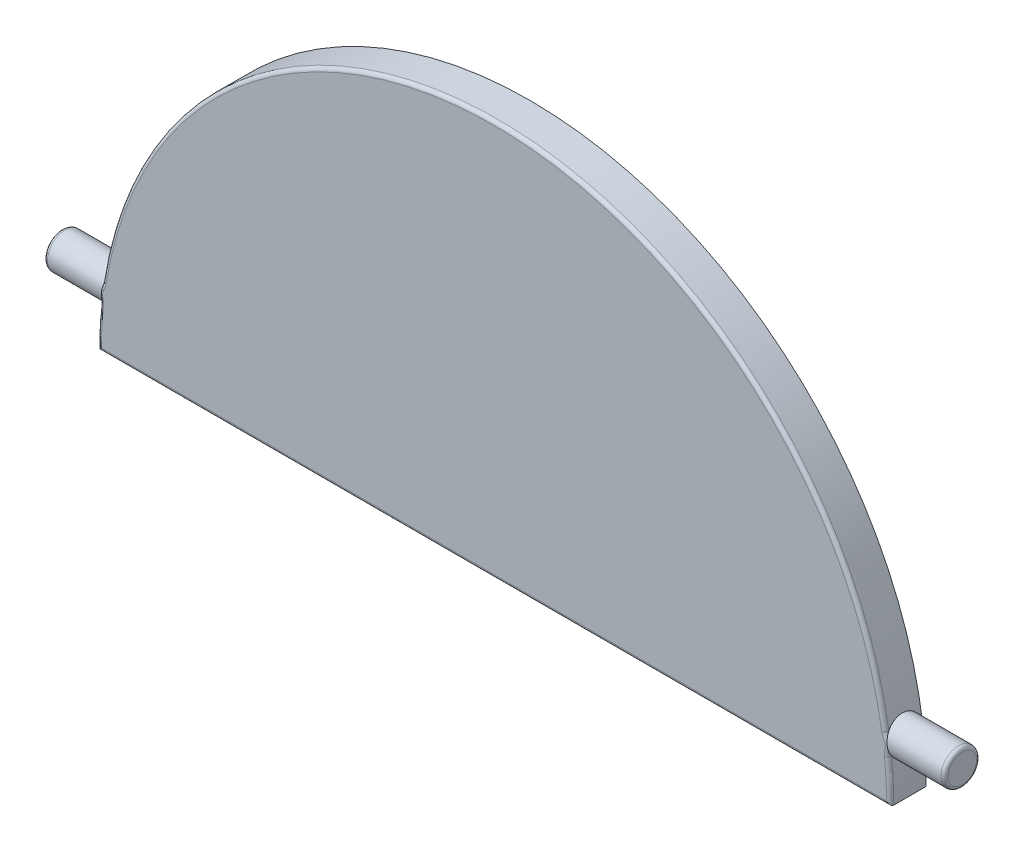
from build123d import *

# Parameters (mm, degrees)
BOSS_EXTRUDE1_DEPTH = 1
SKETCH2_R           = 0.495
BOSS_EXTRUDE2_DEPTH = 12.5
FILLET1_R           = 0.1
FILLET7_R           = 0.1


with BuildPart() as part:
    # Sketch1 → Boss-Extrude1 (new body)
    with BuildSketch(Plane.XY):
        with BuildLine():
            Line((-10.996500042, -10.999999443), (11.003499958, -10.992997297))
            ThreePointArc((11.003499958, -10.992997297), (0, -3e-09), (-10.996500042, -10.999999443))
        make_face()
    extrude(amount=BOSS_EXTRUDE1_DEPTH)

    # Sketch2 → Boss-Extrude2 (add, symmetric)
    with BuildSketch(Plane(origin=(0, 0, 0), x_dir=(0, 0, -1), z_dir=(1, 0, 0))):
        with Locations((-0.495199191, -9.559999443)):
            Circle(SKETCH2_R)
    extrude(amount=BOSS_EXTRUDE2_DEPTH, both=True)

    # Fillet1
    fillet1_edges = [part.edges().sort_by_distance(p)[0] for p in [
        (12.5, -9.559999443, 0.990199191),
        (-12.5, -9.559999443, 0.990199191),
    ]]
    fillet(fillet1_edges, radius=FILLET1_R)

    # Fillet7
    fillet7_edges = [part.edges().sort_by_distance(p)[0] for p in [
        (0, -3e-09, 1),
        (0.003499958, -10.99649837, 1),
    ]]
    fillet(fillet7_edges, radius=FILLET7_R)


solid = part.part
